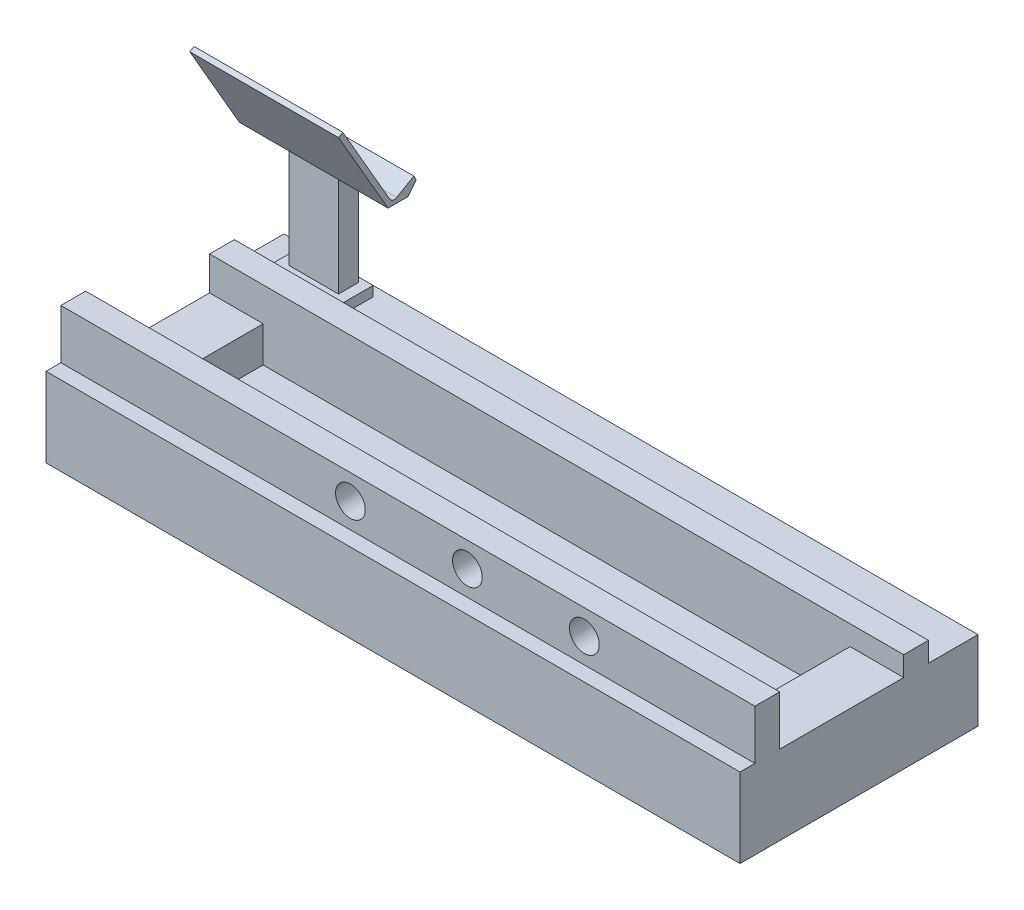
from build123d import *

# Parameters (mm, degrees)
BOSS_EXTRUDE1_DEPTH = 350
SKETCH2_W           = 54
SKETCH2_H           = 125
BOSS_EXTRUDE2_DEPTH = 36
SKETCH4_W           = 54
SKETCH4_H           = 125
BOSS_EXTRUDE3_DEPTH = 50
SKETCH5_R           = 15
CUT_EXTRUDE1_DEPTH  = 25
SKETCH6_W           = 70
SKETCH6_H           = 30
BOSS_EXTRUDE4_DEPTH = 10
SKETCH7_W           = 50
SKETCH7_H           = 20
BOSS_EXTRUDE5_DEPTH = 100
BOSS_EXTRUDE6_DEPTH = 75


with BuildPart() as part:
    # Sketch1 → Boss-Extrude1 (new body, symmetric)
    with BuildSketch(Plane(origin=(0, 0, 0), x_dir=(0, 0, -1), z_dir=(1, 0, 0))):
        Polygon((-120, -30), (120, -30), (120, 50), (70, 50), (70, 70), (45, 70), (45, 0), (-80, 0), (-80, 100), (-105, 100), (-105, 50), (-120, 50), align=None)
    extrude(amount=BOSS_EXTRUDE1_DEPTH, both=True)

    # Sketch2 → Boss-Extrude2 (add)
    with BuildSketch(Plane(origin=(0, 0, 0), x_dir=(1, 0, 0), z_dir=(0, 1, 0))):
        with Locations((-323, -17.5)):
            Rectangle(SKETCH2_W, SKETCH2_H)
    extrude(amount=BOSS_EXTRUDE2_DEPTH)

    # Sketch4 → Boss-Extrude3 (add)
    with BuildSketch(Plane(origin=(0, 0, 0), x_dir=(1, 0, 0), z_dir=(0, 1, 0))):
        with Locations((323, -17.5)):
            Rectangle(SKETCH4_W, SKETCH4_H)
    extrude(amount=BOSS_EXTRUDE3_DEPTH)

    # Sketch5 → Cut-Extrude1 (cut)
    with BuildSketch(Plane(origin=(0, 0, 80), x_dir=(-1, 0, 0), z_dir=(0, 0, -1))):
        with Locations((-178, 75)):
            Circle(SKETCH5_R)
        with Locations((-60, 75)):
            Circle(SKETCH5_R)
        with Locations((58, 75)):
            Circle(SKETCH5_R)
    extrude(amount=-CUT_EXTRUDE1_DEPTH, mode=Mode.SUBTRACT)

    # Sketch6 → Boss-Extrude4 (add)
    with BuildSketch(Plane(origin=(0, 50, 0), x_dir=(1, 0, 0), z_dir=(0, 1, 0))):
        with Locations((-285, 95)):
            Rectangle(SKETCH6_W, SKETCH6_H)
    extrude(amount=BOSS_EXTRUDE4_DEPTH)

    # Sketch7 → Boss-Extrude5 (add)
    with BuildSketch(Plane(origin=(0, 60, 0), x_dir=(1, 0, 0), z_dir=(0, 1, 0))):
        with Locations((-285, 95)):
            Rectangle(SKETCH7_W, SKETCH7_H)
    extrude(amount=BOSS_EXTRUDE5_DEPTH)

    # Sketch10 → Boss-Extrude6 (add, symmetric)
    with BuildSketch(Plane.ZY.offset(285)):
        with BuildLine():
            Line((-105, 160), (-85, 160))
            Line((-85, 160), (-35, 246.602540378))
            Line((-35, 246.602540378), (-39.330127019, 249.102540378))
            Line((-39.330127019, 249.102540378), (-86.830127019, 166.830127019))
            ThreePointArc((-86.830127019, 166.830127019), (-89.866158812, 164.500497887), (-93.660254038, 165))
            Line((-93.660254038, 165), (-110.980762114, 175))
            Line((-110.980762114, 175), (-113.480762114, 170.669872981))
            Line((-113.480762114, 170.669872981), (-105, 160))
        make_face()
    extrude(amount=BOSS_EXTRUDE6_DEPTH, both=True)


solid = part.part
